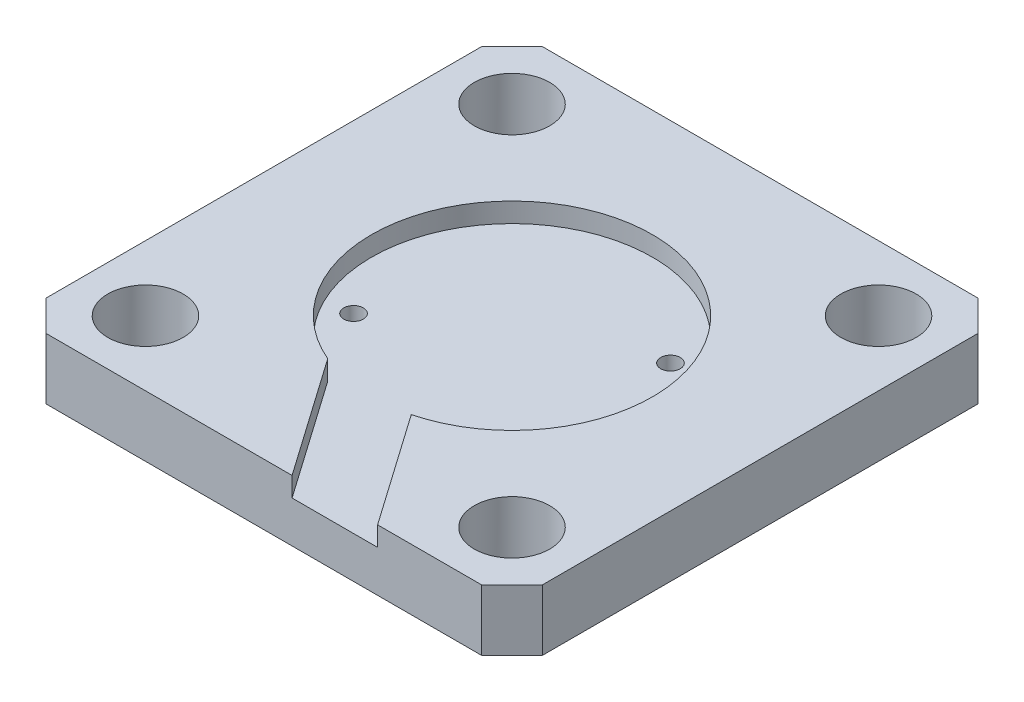
from build123d import *

# Parameters (mm, degrees)
SKETCH1_W           = 40.64
SKETCH1_H           = 40.64
BOSS_EXTRUDE1_DEPTH = 5
CUT_EXTRUDE1_REACH  = 7
SKETCH2_R           = 3.085
CHAMFER1_SIZE       = 2.5
SKETCH3_R           = 11.5
CUT_EXTRUDE2_DEPTH  = 1.6
SKETCH7_R           = 0.8
CUT_EXTRUDE6_DEPTH  = 4.4
CUT_EXTRUDE7_DEPTH  = 1.6


with BuildPart() as part:
    # Sketch1 → Boss-Extrude1 (new body)
    with BuildSketch(Plane(origin=(0, 0, 0), x_dir=(1, 0, 0), z_dir=(0, 1, 0))):
        Rectangle(SKETCH1_W, SKETCH1_H)
    extrude(amount=BOSS_EXTRUDE1_DEPTH)

    # Sketch2 → Cut-Extrude1 (cut, up to next)
    with BuildSketch(Plane(origin=(0, 5, 0), x_dir=(1, 0, 0), z_dir=(0, 1, 0)), mode=Mode.PRIVATE) as cut_extrude1_sk1:
        with Locations((-15, 15)):
            Circle(SKETCH2_R)
    cut_extrude1_tool1 = extrude(cut_extrude1_sk1.sketch, amount=-CUT_EXTRUDE1_REACH, mode=Mode.PRIVATE) & part.part
    add(cut_extrude1_tool1.solids().sort_by_distance((-15, 5, -15))[0], mode=Mode.SUBTRACT)
    # Sketch2 → Cut-Extrude1 (cut, up to next)
    with BuildSketch(Plane(origin=(0, 5, 0), x_dir=(1, 0, 0), z_dir=(0, 1, 0)), mode=Mode.PRIVATE) as cut_extrude1_sk2:
        with Locations((15, 15)):
            Circle(SKETCH2_R)
    cut_extrude1_tool2 = extrude(cut_extrude1_sk2.sketch, amount=-CUT_EXTRUDE1_REACH, mode=Mode.PRIVATE) & part.part
    add(cut_extrude1_tool2.solids().sort_by_distance((15, 5, -15))[0], mode=Mode.SUBTRACT)
    # Sketch2 → Cut-Extrude1 (cut, up to next)
    with BuildSketch(Plane(origin=(0, 5, 0), x_dir=(1, 0, 0), z_dir=(0, 1, 0)), mode=Mode.PRIVATE) as cut_extrude1_sk3:
        with Locations((15, -15)):
            Circle(SKETCH2_R)
    cut_extrude1_tool3 = extrude(cut_extrude1_sk3.sketch, amount=-CUT_EXTRUDE1_REACH, mode=Mode.PRIVATE) & part.part
    add(cut_extrude1_tool3.solids().sort_by_distance((15, 5, 15))[0], mode=Mode.SUBTRACT)
    # Sketch2 → Cut-Extrude1 (cut, up to next)
    with BuildSketch(Plane(origin=(0, 5, 0), x_dir=(1, 0, 0), z_dir=(0, 1, 0)), mode=Mode.PRIVATE) as cut_extrude1_sk4:
        with Locations((-15, -15)):
            Circle(SKETCH2_R)
    cut_extrude1_tool4 = extrude(cut_extrude1_sk4.sketch, amount=-CUT_EXTRUDE1_REACH, mode=Mode.PRIVATE) & part.part
    add(cut_extrude1_tool4.solids().sort_by_distance((-15, 5, 15))[0], mode=Mode.SUBTRACT)

    # Chamfer1
    chamfer1_edges = [part.edges().sort_by_distance(p)[0] for p in [
        (20.32, 2.5, 20.32),
        (-20.32, 2.5, 20.32),
        (-20.32, 2.5, -20.32),
        (20.32, 2.5, -20.32),
    ]]
    chamfer(chamfer1_edges, length=CHAMFER1_SIZE)

    # Sketch3 → Cut-Extrude2 (cut)
    with BuildSketch(Plane(origin=(0, 5, 0), x_dir=(1, 0, 0), z_dir=(0, 1, 0))):
        Circle(SKETCH3_R)
    extrude(amount=-CUT_EXTRUDE2_DEPTH, mode=Mode.SUBTRACT)

    # Sketch7 → Cut-Extrude6 (cut, through all)
    with BuildSketch(Plane(origin=(0, 3.4, 0), x_dir=(1, 0, 0), z_dir=(0, 1, 0))):
        with Locations((-8.243053696, -4.727309167)):
            Circle(SKETCH7_R)
        with Locations((8.243053696, 4.727309167)):
            Circle(SKETCH7_R)
    extrude(amount=-CUT_EXTRUDE6_DEPTH, mode=Mode.SUBTRACT)

    # Sketch8 → Cut-Extrude7 (cut)
    with BuildSketch(Plane(origin=(0, 5, 0), x_dir=(1, 0, 0), z_dir=(0, 1, 0))):
        with BuildLine():
            ThreePointArc((2.886406189, -11.131875822), (-0.850588117, -11.468500332), (-4.497034553, -10.584265692))
            Line((-4.497034553, -10.584265692), (2.32, -20.32))
            Line((2.32, -20.32), (9.32, -20.32))
            Line((9.32, -20.32), (2.886406189, -11.131875822))
        make_face()
    extrude(amount=-CUT_EXTRUDE7_DEPTH, mode=Mode.SUBTRACT)


solid = part.part
